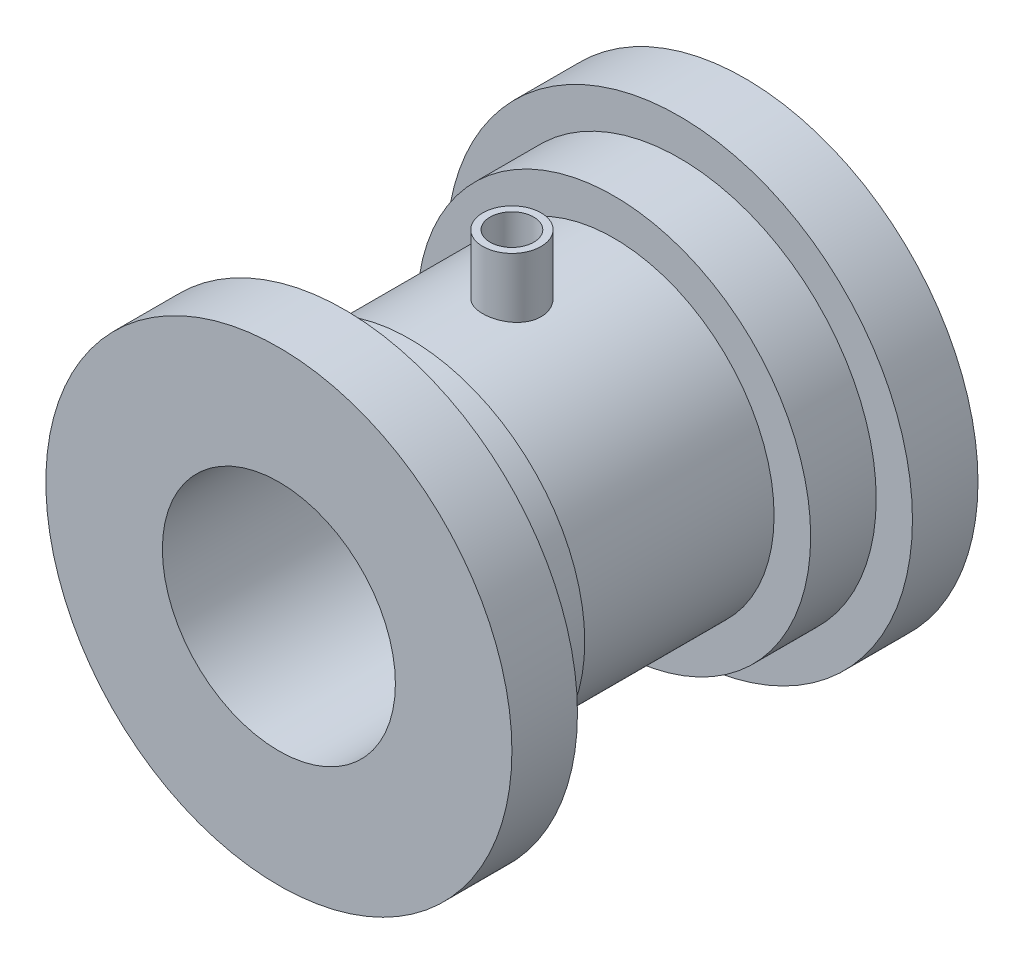
from build123d import *

# Parameters (mm, degrees)
BOSS_EXTRUDE1_START     = 22
SKETCH3_R               = 4
BOSS_EXTRUDE1_DEPTH     = 8
BOSS_EXTRUDE2_START     = -2e-06
SKETCH4_R               = 4
BOSS_EXTRUDE2_DEPTH     = 0.366694
SKETCH2_R               = 3
CUT_EXTRUDE2_DEPTH      = 33
CUT_EXTRUDE2_DEPTH_BACK = 33


with BuildPart() as part:
    # Sketch1 → Revolve1 (revolve)
    with BuildSketch(Plane(origin=(0, 0, 0), x_dir=(0, 0, -1), z_dir=(1, 0, 0))):
        Polygon((-22.985422917, 16), (-22.985422917, 32), (-13.985422917, 32), (-13.985422917, 24), (-4.985422917, 24), (-4.985422917, 22), (23.014577083, 22), (23.014577083, 27.022421525), (32.014577083, 27.022421525), (32.014577083, 32), (41.014577083, 32), (41.014577083, 16), align=None)
    revolve(axis=Axis((0, 0, 0), (0, 0, -1)))



with BuildPart() as body_2:
    # Sketch3 → Boss-Extrude1 (new body)
    with BuildSketch(Plane(origin=(0, 0, 0), x_dir=(1, 0, 0), z_dir=(0, 1, 0)).offset(BOSS_EXTRUDE1_START)):
        with Locations((0, 9.014577083)):
            Circle(SKETCH3_R)
    extrude(amount=BOSS_EXTRUDE1_DEPTH)


with BuildPart() as part_1:
    add(part.part)

    add(body_2.part)  # Boss-Extrude2 merges body 2
    # Sketch4 → Boss-Extrude2 (add)
    with BuildSketch(Plane.XZ.offset(-22).offset(BOSS_EXTRUDE2_START)):
        with Locations((0, -9.014577083)):
            Circle(SKETCH4_R)
    extrude(amount=BOSS_EXTRUDE2_DEPTH)

    # Sketch2 → Cut-Extrude2 (cut, two sides)
    with BuildSketch(Plane(origin=(0, 0, 0), x_dir=(1, 0, 0), z_dir=(0, 1, 0))) as cut_extrude2_sk:
        with Locations((0, 9.014577083)):
            Circle(SKETCH2_R)
    extrude(amount=CUT_EXTRUDE2_DEPTH, mode=Mode.SUBTRACT)
    extrude(cut_extrude2_sk.sketch, amount=-CUT_EXTRUDE2_DEPTH_BACK, mode=Mode.SUBTRACT)


solid = part_1.part
